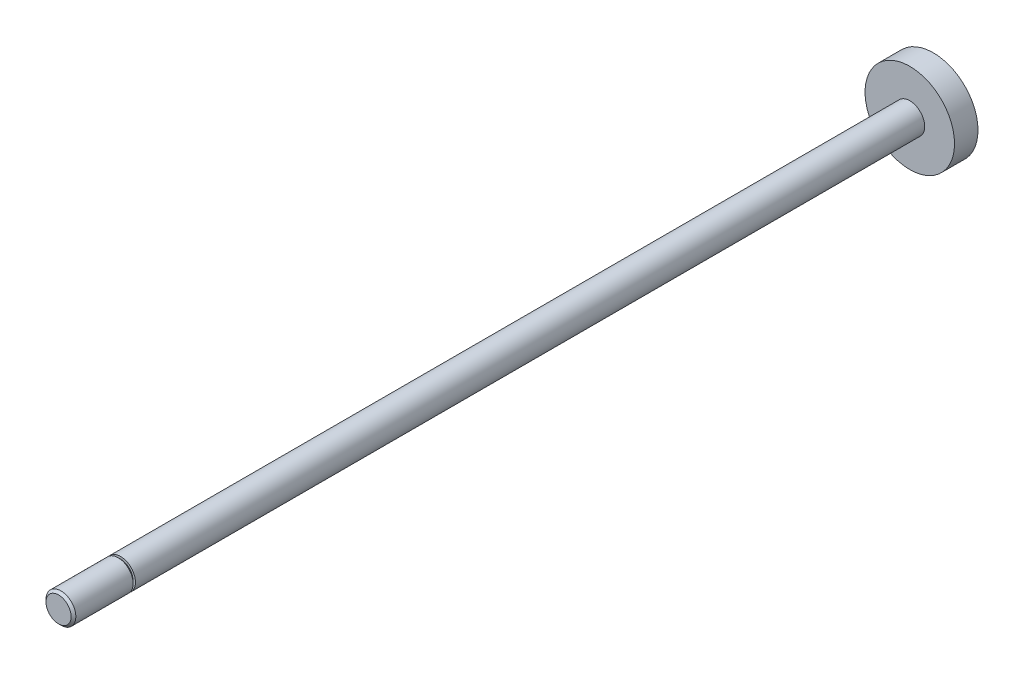
from build123d import *

# Parameters (mm, degrees)
SKETCH1_R      = 3.175
EXTRUDE1_DEPTH = 183.769
SKETCH2_R      = 9.525
PISTON_DEPTH   = 2.5


with BuildPart() as part:
    # Sketch1 → Extrude1 (new body)
    with BuildSketch(Plane.XY):
        Circle(SKETCH1_R)
    extrude(amount=EXTRUDE1_DEPTH)

    # Sketch2 → Piston (add, symmetric)
    with BuildSketch(Plane.XY):
        Circle(SKETCH2_R)
    extrude(amount=PISTON_DEPTH, both=True)

    # Sketch3 → Threads (revolve, cut)
    with BuildSketch(Plane(origin=(0, 0, 0), x_dir=(0, 0, -1), z_dir=(1, 0, 0))):
        Polygon((-183.769, 9.525), (-170.569, 9.525), (-170.569, 2.675), (-171.069, 2.675), (-171.069, 3.175), (-183.269, 3.175), (-183.769, 2.675), align=None)
    revolve(axis=Axis((0, 0, 0), (0, 0, 1)), mode=Mode.SUBTRACT)


solid = part.part
